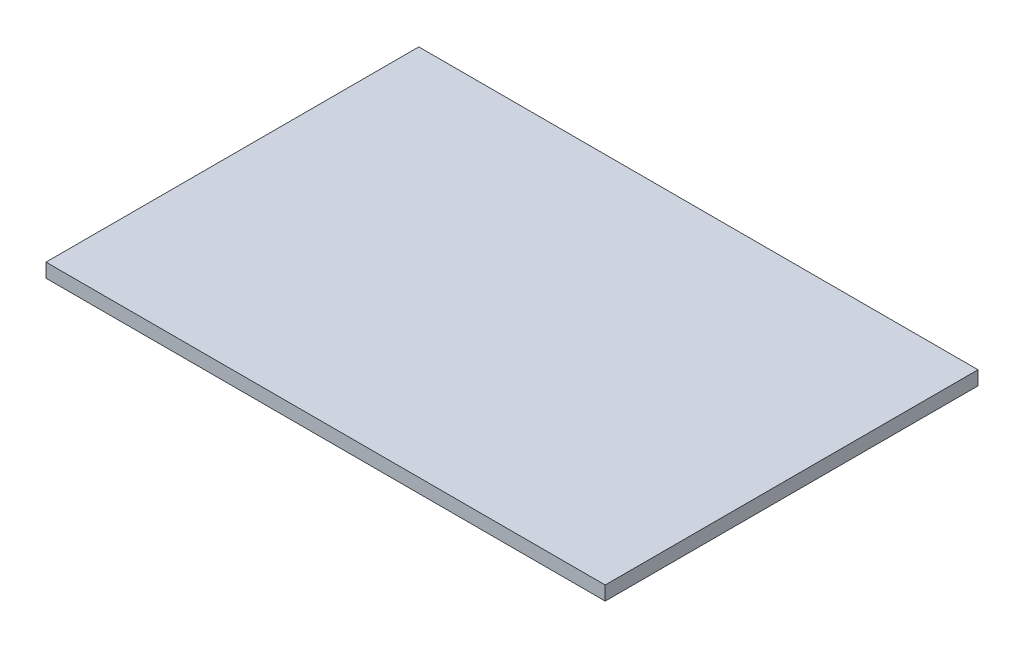
from build123d import *

# Parameters (mm, degrees)
CROQUIS1_W              = 12
CROQUIS1_H              = 8
SALIENTE_EXTRUIR1_DEPTH = 0.3


with BuildPart() as part:
    # Croquis1 → Saliente-Extruir1 (new body)
    with BuildSketch(Plane(origin=(0, 0, 0), x_dir=(1, 0, 0), z_dir=(0, 1, 0))):
        Rectangle(CROQUIS1_W, CROQUIS1_H)
    extrude(amount=SALIENTE_EXTRUIR1_DEPTH)


solid = part.part
